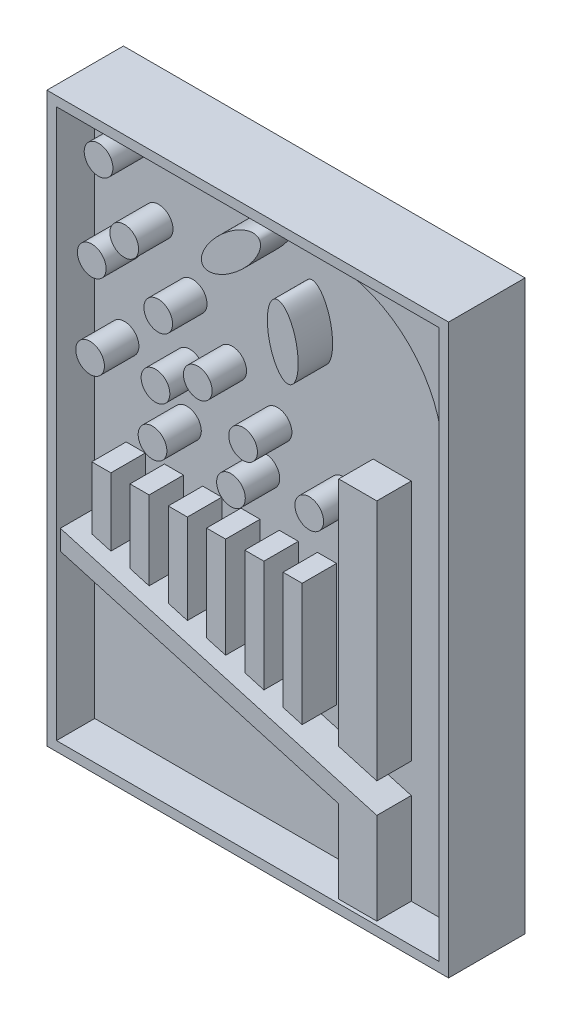
from build123d import *

# Parameters (mm, degrees)
SKETCH_1_W          = 210
SKETCH_1_H          = 297
EXTRUDE_1_DEPTH     = 40
SKETCH_2_W          = 200
SKETCH_2_H          = 287
CUT_EXTRUDE_1_DEPTH = 20
SKETCH_3_R          = 7.5
EXTRUDE_2_DEPTH     = 18
EXTRUDE_3_DEPTH     = 18


with BuildPart() as part:
    # 草圖1 → 填料-伸長1 (new body)
    with BuildSketch(Plane.XY):
        Rectangle(SKETCH_1_W, SKETCH_1_H)
    extrude(amount=-EXTRUDE_1_DEPTH)

    # 草圖2 → 除料-伸長1 (cut)
    with BuildSketch(Plane.XY):
        Rectangle(SKETCH_2_W, SKETCH_2_H)
    extrude(amount=-CUT_EXTRUDE_1_DEPTH, mode=Mode.SUBTRACT)

    # 草圖3 → 填料-伸長2 (add)
    with BuildSketch(Plane.XY.offset(-20)):
        Polygon((45.565174328, -143.5), (65.486710308, -143.5), (65.486710308, -95.625994785), (-100, -48.364191076), (-100, -58.764014226), (45.565174328, -100.336371808), align=None)
        Polygon((65.486710308, -80.02626006), (65.486710308, 46.771617849), (45.565174328, 46.771617849), (45.565174328, -74.336813933), align=None)
        Polygon((16.43949597, -71.218643102), (26.43949597, -74.074570543), (26.43949597, -10.050257104), (16.43949597, -10.050257104), align=None)
        Polygon((-73.56050403, -10.050257104), (-83.56050403, -10.050257104), (-83.56050403, -42.659368692), (-73.56050403, -45.515296133), align=None)
        Polygon((-53.56050403, -10.050257104), (-63.56050403, -10.050257104), (-63.56050403, -48.371223574), (-53.56050403, -51.227151015), align=None)
        Polygon((-33.56050403, -56.939005897), (-33.56050403, -10.050257104), (-43.56050403, -10.050257104), (-43.56050403, -54.083078456), align=None)
        Polygon((-13.56050403, -62.650860779), (-13.56050403, -10.050257104), (-23.56050403, -10.050257104), (-23.56050403, -59.794933338), align=None)
        Polygon((6.43949597, -10.050257104), (-3.56050403, -10.050257104), (-3.56050403, -65.50678822), (6.43949597, -68.362715661), align=None)
        with Locations((-80, 128.5)):
            Circle(SKETCH_3_R)
        with Locations((-66.570869478, 98.5)):
            Circle(SKETCH_3_R)
        with Locations((-48.804847533, 73.5)):
            Circle(SKETCH_3_R)
        with Locations((-28.128524571, 53.5)):
            Circle(SKETCH_3_R)
        with Locations((30.154024986, 23.5)):
            Circle(SKETCH_3_R)
        with Locations((-4.436239635, 37.595056508)):
            Circle(SKETCH_3_R)
        with Locations((-83.56050403, 81.097019172)):
            Circle(SKETCH_3_R)
        with Locations((-50.239783165, 41.080389262)):
            Circle(SKETCH_3_R)
        with Locations((-10.782679355, 13.507027121)):
            Circle(SKETCH_3_R)
        with Locations((-84.425125003, 36.578615851)):
            Circle(SKETCH_3_R)
        with Locations((-51.787267775, 14.491790055)):
            Circle(SKETCH_3_R)
        with BuildLine():
            add(Edge.make_bspline(
                [(3.812950522, 134.663232329), (-4.971133753, 144.233491649), (-22.472536431, 119.353413889), (-39.973939109, 94.473336129), (-13.688452156, 109.783154569), (12.597034797, 125.092973009), (3.812950522, 134.663232329)],
                knots=[0, 0, 0, 2.094395102, 2.094395102, 4.188790205, 4.188790205, 6.283185307, 6.283185307, 6.283185307], degree=2, weights=[1, 0.5, 1, 0.5, 1, 0.5, 1]))
        make_face()
        with BuildLine():
            add(Edge.make_bspline(
                [(13.075828168, 111.85142679), (0.297213563, 109.515402653), (11.533016148, 84.171918363), (22.768818733, 58.828434072), (24.311630754, 86.5079425), (25.854442774, 114.187450927), (13.075828168, 111.85142679)],
                knots=[0, 0, 0, 2.094395102, 2.094395102, 4.188790205, 4.188790205, 6.283185307, 6.283185307, 6.283185307], degree=2, weights=[1, 0.5, 1, 0.5, 1, 0.5, 1]))
        make_face()
    extrude(amount=EXTRUDE_2_DEPTH)

    # 草圖4 → 填料-伸長3 (add)
    with BuildSketch(Plane.XY.offset(-20)):
        with BuildLine():
            Line((40, 143.5), (100, 143.5))
            Line((100, 143.5), (100, 83.5))
            ThreePointArc((100, 83.5), (82.426406871, 125.926406871), (40, 143.5))
        make_face()
    extrude(amount=EXTRUDE_3_DEPTH)


solid = part.part
